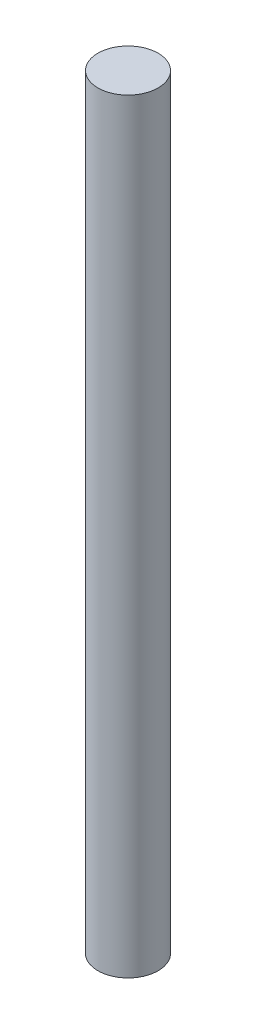
from build123d import *

# Parameters (mm, degrees)
SKETCH1_R           = 6
BOSS_EXTRUDE1_DEPTH = 304.8
SKETCH2_R           = 11.261992414
CUT_EXTRUDE1_DEPTH  = 152.4


with BuildPart() as part:
    # Sketch1 → Boss-Extrude1 (new body)
    with BuildSketch(Plane(origin=(0, 0, 0), x_dir=(1, 0, 0), z_dir=(0, 1, 0))):
        Circle(SKETCH1_R)
    extrude(amount=BOSS_EXTRUDE1_DEPTH)

    # Sketch2 → Cut-Extrude1 (cut)
    with BuildSketch(Plane.XZ):
        Circle(SKETCH2_R)
    extrude(amount=-CUT_EXTRUDE1_DEPTH, mode=Mode.SUBTRACT)


solid = part.part
